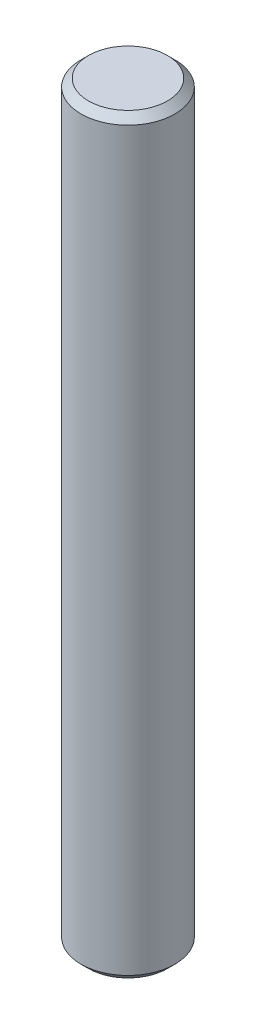
from build123d import *

# Parameters (mm, degrees)
SKETCH1_R           = 12.5
BOSS_EXTRUDE1_DEPTH = 100
CHAMFER1_SIZE       = 2


with BuildPart() as part:
    # Sketch1 → Boss-Extrude1 (new body, symmetric)
    with BuildSketch(Plane(origin=(0, 0, 0), x_dir=(1, 0, 0), z_dir=(0, 1, 0))):
        Circle(SKETCH1_R)
    extrude(amount=BOSS_EXTRUDE1_DEPTH, both=True)

    # Chamfer1
    chamfer1_edges = [part.edges().sort_by_distance(p)[0] for p in [
        (-12.5, -100, 0),
        (-12.5, 100, 0),
    ]]
    chamfer(chamfer1_edges, length=CHAMFER1_SIZE)


solid = part.part
